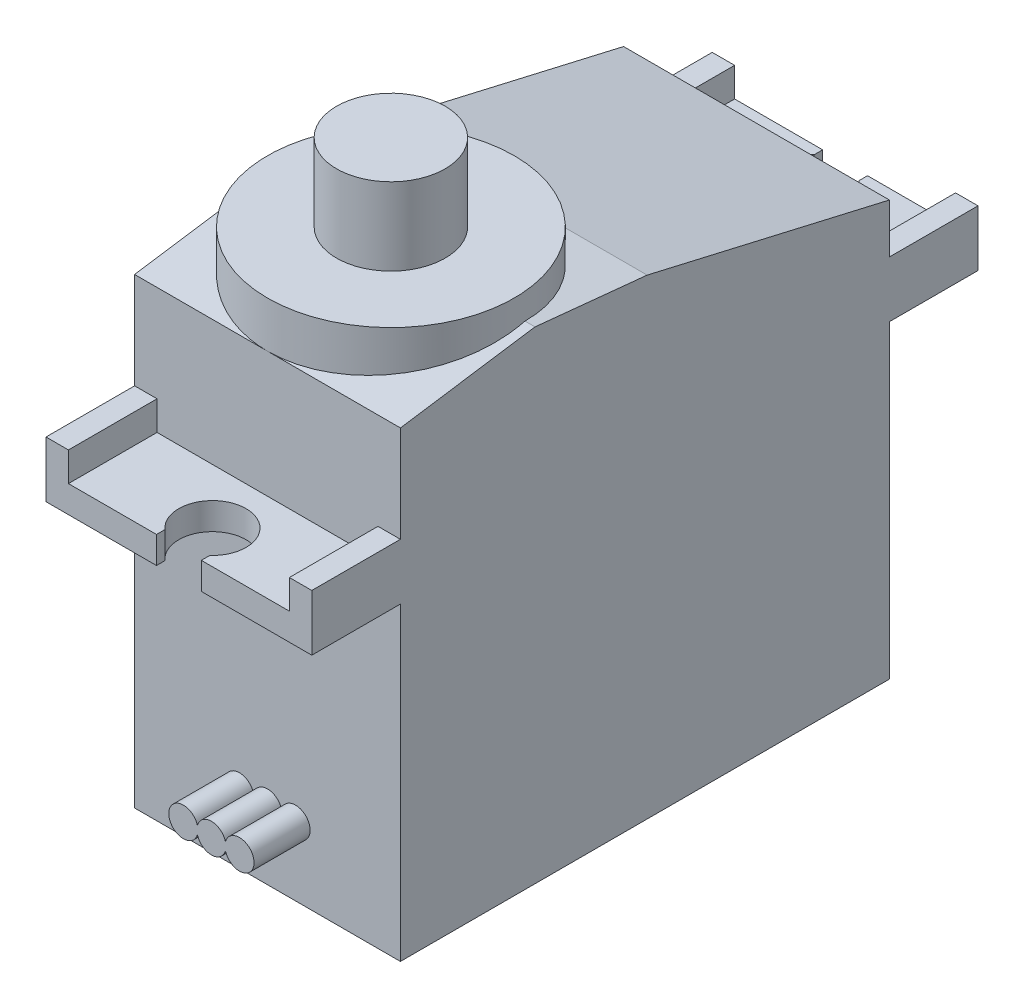
from build123d import *

# Parameters (mm, degrees)
SKETCH2_W           = 11.85
SKETCH2_H           = 21.8
BOSS_EXTRUDE1_DEPTH = 13.8
SKETCH3_W           = 11.85
SKETCH3_H           = 29.7
BOSS_EXTRUDE2_DEPTH = 1.2
SKETCH4_R           = 1.5
CUT_EXTRUDE11_DEPTH = 1.2
SKETCH5_W           = 2
SKETCH5_H           = 2
CUT_EXTRUDE12_DEPTH = 1.2
SKETCH6_R           = 5.5
BOSS_EXTRUDE3_DEPTH = 7.65
SKETCH7_R           = 2.42
BOSS_EXTRUDE4_DEPTH = 3.45
BOSS_EXTRUDE5_DEPTH = 11.85
SKETCH9_W           = 1
SKETCH9_H           = 3.95
BOSS_EXTRUDE6_DEPTH = 1.3
BOSS_EXTRUDE7_DEPTH = 2.5


with BuildPart() as part:
    # Sketch2 → Boss-Extrude1 (new body)
    with BuildSketch(Plane(origin=(0, 0, 0), x_dir=(1, 0, 0), z_dir=(0, 1, 0))):
        Rectangle(SKETCH2_W, SKETCH2_H)
    extrude(amount=-BOSS_EXTRUDE1_DEPTH)

    # Sketch3 → Boss-Extrude2 (add)
    with BuildSketch(Plane(origin=(0, 0, 0), x_dir=(1, 0, 0), z_dir=(0, 1, 0))):
        Rectangle(SKETCH3_W, SKETCH3_H)
    extrude(amount=BOSS_EXTRUDE2_DEPTH)

    # Sketch4 → Cut-Extrude11 (cut)
    with BuildSketch(Plane(origin=(0, 1.2, 0), x_dir=(1, 0, 0), z_dir=(0, 1, 0))):
        with Locations((0, 13.355)):
            Circle(SKETCH4_R)
        with Locations((0, -13.355)):
            Circle(SKETCH4_R)
    extrude(amount=-CUT_EXTRUDE11_DEPTH, mode=Mode.SUBTRACT)

    # Sketch5 → Cut-Extrude12 (cut)
    with BuildSketch(Plane(origin=(0, 1.2, 0), x_dir=(1, 0, 0), z_dir=(0, 1, 0))):
        with Locations((0, 14.85)):
            Rectangle(SKETCH5_W, SKETCH5_H)
        with Locations((0, -14.85)):
            Rectangle(SKETCH5_W, SKETCH5_H)
    extrude(amount=-CUT_EXTRUDE12_DEPTH, mode=Mode.SUBTRACT)

    # Sketch6 → Boss-Extrude3 (add)
    with BuildSketch(Plane(origin=(0, 1.2, 0), x_dir=(1, 0, 0), z_dir=(0, 1, 0))):
        with Locations((0, -5.4)):
            Circle(SKETCH6_R)
    extrude(amount=BOSS_EXTRUDE3_DEPTH)

    # Sketch7 → Boss-Extrude4 (add)
    with BuildSketch(Plane(origin=(0, 8.85, 0), x_dir=(1, 0, 0), z_dir=(0, 1, 0))):
        with Locations((0, -5.4)):
            Circle(SKETCH7_R)
    extrude(amount=BOSS_EXTRUDE4_DEPTH)

    # Sketch8 → Boss-Extrude5 (add)
    with BuildSketch(Plane(origin=(5.925, 0, 0), x_dir=(0, 0, -1), z_dir=(1, 0, 0))):
        Polygon((-10.9, 1.2), (-10.9, 6.8), (-4.9, 7.7), (0.1, 7.2), (10.9, 4.7), (10.9, 1.2), align=None)
    extrude(amount=-BOSS_EXTRUDE5_DEPTH)

    # Sketch9 → Boss-Extrude6 (add)
    with BuildSketch(Plane(origin=(0, 1.2, 0), x_dir=(1, 0, 0), z_dir=(0, 1, 0))):
        with Locations((5.425, -12.875)):
            Rectangle(SKETCH9_W, SKETCH9_H)
        with Locations((-5.425, -12.875)):
            Rectangle(SKETCH9_W, SKETCH9_H)
        with Locations((-5.425, 12.875)):
            Rectangle(SKETCH9_W, SKETCH9_H)
        with Locations((5.425, 12.875)):
            Rectangle(SKETCH9_W, SKETCH9_H)
    extrude(amount=BOSS_EXTRUDE6_DEPTH)

    # Sketch10 → Boss-Extrude7 (add)
    with BuildSketch(Plane.XY.offset(10.9)):
        with BuildLine():
            ThreePointArc((-0.625, -10.928535711), (0, -11.4), (0.625, -10.928535711))
            ThreePointArc((0.625, -10.928535711), (1.9, -10.75), (0.625, -10.571464289))
            ThreePointArc((0.625, -10.571464289), (0, -10.1), (-0.625, -10.571464289))
            ThreePointArc((-0.625, -10.571464289), (-1.9, -10.75), (-0.625, -10.928535711))
        make_face()
    extrude(amount=BOSS_EXTRUDE7_DEPTH)


solid = part.part
